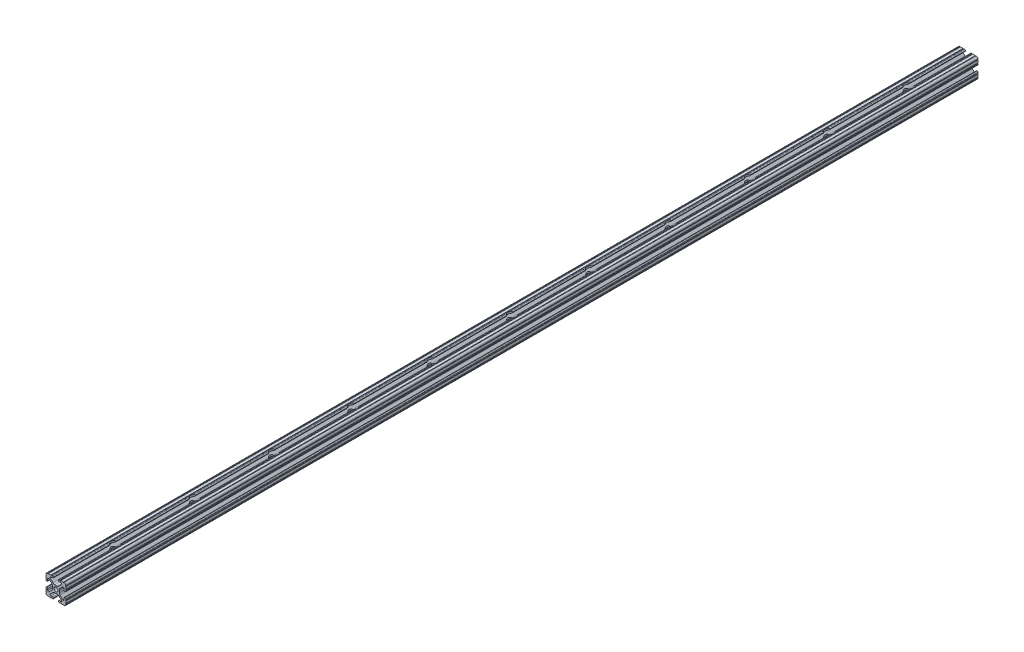
from build123d import *

# Parameters (mm, degrees)
SKETCH1_R       = 2.6035
EXTRUDE1_DEPTH  = 1168.4
LPATTERN1_COUNT = 11
LPATTERN1_PITCH = 101.6


with BuildPart() as part:
    # Sketch1 → Extrude1 (new body)
    with BuildSketch(Plane.XY):
        with BuildLine():
            Line((-7.207036008, 8.724370562), (-3.898272566, 5.423169045))
            ThreePointArc((-3.898272566, 5.423169045), (-2.869120213, 4.736787962), (-1.655778399, 4.4958))
            Line((-1.655778399, 4.4958), (1.655778399, 4.4958))
            ThreePointArc((1.655778399, 4.4958), (2.869120213, 4.736787962), (3.898272566, 5.423169045))
            Line((3.898272566, 5.423169045), (7.207036008, 8.724370562))
            ThreePointArc((7.207036008, 8.724370562), (7.432222385, 9.85140422), (6.476788598, 10.4902))
            Line((6.476788598, 10.4902), (4.287512407, 10.4902))
            ThreePointArc((4.287512407, 10.4902), (3.54574862, 10.79744862), (3.2385, 11.539212407))
            Line((3.2385, 11.539212407), (3.2385, 11.650987593))
            ThreePointArc((3.2385, 11.650987593), (3.54574862, 12.39275138), (4.287512407, 12.7))
            Line((4.287512407, 12.7), (5.317126718, 12.7))
            ThreePointArc((5.317126718, 12.7), (5.825126718, 12.192), (6.333126718, 12.7))
            Line((6.333126718, 12.7), (9.550443118, 12.7))
            ThreePointArc((9.550443118, 12.7), (10.058366869, 12.192000006), (10.566443095, 12.699847501))
            ThreePointArc((10.566443095, 12.699847501), (12.082537762, 12.08250727), (12.699846982, 10.566399977))
            ThreePointArc((12.699846982, 10.566399977), (12.192000006, 10.058323491), (12.7, 9.5504))
            Line((12.7, 9.5504), (12.7, 6.3330836))
            ThreePointArc((12.7, 6.3330836), (12.192, 5.8250836), (12.7, 5.3170836))
            Line((12.7, 5.3170836), (12.7, 4.287469289))
            ThreePointArc((12.7, 4.287469289), (12.39275138, 3.545705502), (11.650987593, 3.238456882))
            Line((11.650987593, 3.238456882), (11.539212407, 3.238456882))
            ThreePointArc((11.539212407, 3.238456882), (10.79744862, 3.545705502), (10.4902, 4.287469289))
            Line((10.4902, 4.287469289), (10.4902, 6.402089023))
            ThreePointArc((10.4902, 6.402089023), (9.856505071, 7.351067942), (8.737131347, 7.129408934))
            Line((8.737131347, 7.129408934), (5.441005833, 3.840816462))
            ThreePointArc((5.441005833, 3.840816462), (4.750877967, 2.809883091), (4.5085, 1.593185507))
            Line((4.5085, 1.593185507), (4.5085, -1.593185507))
            ThreePointArc((4.5085, -1.593185507), (4.750877967, -2.809883091), (5.441005833, -3.840816462))
            Line((5.441005833, -3.840816462), (8.737131347, -7.129408934))
            ThreePointArc((8.737131347, -7.129408934), (9.856505071, -7.351067942), (10.4902, -6.402089023))
            Line((10.4902, -6.402089023), (10.4902, -4.287469289))
            ThreePointArc((10.4902, -4.287469289), (10.79744862, -3.545705502), (11.539212407, -3.238456882))
            Line((11.539212407, -3.238456882), (11.650987593, -3.238456882))
            ThreePointArc((11.650987593, -3.238456882), (12.39275138, -3.545705502), (12.7, -4.287469289))
            Line((12.7, -4.287469289), (12.7, -5.3170836))
            ThreePointArc((12.7, -5.3170836), (12.192, -5.8250836), (12.7, -6.3330836))
            Line((12.7, -6.3330836), (12.7, -9.5504))
            ThreePointArc((12.7, -9.5504), (12.192000006, -10.058323491), (12.699846982, -10.566399977))
            ThreePointArc((12.699846982, -10.566399977), (12.082537762, -12.08250727), (10.566443095, -12.699847501))
            ThreePointArc((10.566443095, -12.699847501), (10.058366869, -12.192000006), (9.550443118, -12.7))
            Line((9.550443118, -12.7), (6.333126718, -12.7))
            ThreePointArc((6.333126718, -12.7), (5.825126718, -12.192), (5.317126718, -12.7))
            Line((5.317126718, -12.7), (4.287512407, -12.7))
            ThreePointArc((4.287512407, -12.7), (3.54574862, -12.39275138), (3.2385, -11.650987593))
            Line((3.2385, -11.650987593), (3.2385, -11.539212407))
            ThreePointArc((3.2385, -11.539212407), (3.54574862, -10.79744862), (4.287512407, -10.4902))
            Line((4.287512407, -10.4902), (6.416408329, -10.4902))
            ThreePointArc((6.416408329, -10.4902), (7.41473083, -9.822813117), (7.179650497, -8.645192506))
            Line((7.179650497, -8.645192506), (3.952270251, -5.423690499))
            ThreePointArc((3.952270251, -5.423690499), (2.922936451, -4.736929036), (1.709253557, -4.4958))
            Line((1.709253557, -4.4958), (-1.709253557, -4.4958))
            ThreePointArc((-1.709253557, -4.4958), (-2.922936451, -4.736929036), (-3.952270251, -5.423690499))
            Line((-3.952270251, -5.423690499), (-7.179650497, -8.645192506))
            ThreePointArc((-7.179650497, -8.645192506), (-7.41473083, -9.822813117), (-6.416408329, -10.4902))
            Line((-6.416408329, -10.4902), (-4.287512407, -10.4902))
            ThreePointArc((-4.287512407, -10.4902), (-3.54574862, -10.79744862), (-3.2385, -11.539212407))
            Line((-3.2385, -11.539212407), (-3.2385, -11.650987593))
            ThreePointArc((-3.2385, -11.650987593), (-3.54574862, -12.39275138), (-4.287512407, -12.7))
            Line((-4.287512407, -12.7), (-5.317126718, -12.7))
            ThreePointArc((-5.317126718, -12.7), (-5.825126718, -12.192), (-6.333126718, -12.7))
            Line((-6.333126718, -12.7), (-9.550443118, -12.7))
            ThreePointArc((-9.550443118, -12.7), (-10.058366869, -12.192000006), (-10.566443095, -12.699847501))
            ThreePointArc((-10.566443095, -12.699847501), (-12.082537762, -12.08250727), (-12.699846982, -10.566399977))
            ThreePointArc((-12.699846982, -10.566399977), (-12.192000006, -10.058323491), (-12.7, -9.5504))
            Line((-12.7, -9.5504), (-12.7, -6.3330836))
            ThreePointArc((-12.7, -6.3330836), (-12.192, -5.8250836), (-12.7, -5.3170836))
            Line((-12.7, -5.3170836), (-12.7, -4.287469289))
            ThreePointArc((-12.7, -4.287469289), (-12.39275138, -3.545705502), (-11.650987593, -3.238456882))
            Line((-11.650987593, -3.238456882), (-11.539212407, -3.238456882))
            ThreePointArc((-11.539212407, -3.238456882), (-10.79744862, -3.545705502), (-10.4902, -4.287469289))
            Line((-10.4902, -4.287469289), (-10.4902, -6.402089023))
            ThreePointArc((-10.4902, -6.402089023), (-9.856505071, -7.351067942), (-8.737131347, -7.129408934))
            Line((-8.737131347, -7.129408934), (-5.441005833, -3.840816462))
            ThreePointArc((-5.441005833, -3.840816462), (-4.750877967, -2.809883091), (-4.5085, -1.593185507))
            Line((-4.5085, -1.593185507), (-4.5085, 1.593185507))
            ThreePointArc((-4.5085, 1.593185507), (-4.750877967, 2.809883091), (-5.441005833, 3.840816462))
            Line((-5.441005833, 3.840816462), (-8.737131347, 7.129408934))
            ThreePointArc((-8.737131347, 7.129408934), (-9.856505071, 7.351067942), (-10.4902, 6.402089023))
            Line((-10.4902, 6.402089023), (-10.4902, 4.287469289))
            ThreePointArc((-10.4902, 4.287469289), (-10.79744862, 3.545705502), (-11.539212407, 3.238456882))
            Line((-11.539212407, 3.238456882), (-11.650987593, 3.238456882))
            ThreePointArc((-11.650987593, 3.238456882), (-12.39275138, 3.545705502), (-12.7, 4.287469289))
            Line((-12.7, 4.287469289), (-12.7, 5.3170836))
            ThreePointArc((-12.7, 5.3170836), (-12.192, 5.8250836), (-12.7, 6.3330836))
            Line((-12.7, 6.3330836), (-12.7, 9.5504))
            ThreePointArc((-12.7, 9.5504), (-12.192000006, 10.058323491), (-12.699846982, 10.566399977))
            ThreePointArc((-12.699846982, 10.566399977), (-12.082537762, 12.08250727), (-10.566443095, 12.699847501))
            ThreePointArc((-10.566443095, 12.699847501), (-10.058366869, 12.192000006), (-9.550443118, 12.7))
            Line((-9.550443118, 12.7), (-6.333126718, 12.7))
            ThreePointArc((-6.333126718, 12.7), (-5.825126718, 12.192), (-5.317126718, 12.7))
            Line((-5.317126718, 12.7), (-4.287512407, 12.7))
            ThreePointArc((-4.287512407, 12.7), (-3.54574862, 12.39275138), (-3.2385, 11.650987593))
            Line((-3.2385, 11.650987593), (-3.2385, 11.539212407))
            ThreePointArc((-3.2385, 11.539212407), (-3.54574862, 10.79744862), (-4.287512407, 10.4902))
            Line((-4.287512407, 10.4902), (-6.476788598, 10.4902))
            ThreePointArc((-6.476788598, 10.4902), (-7.432222385, 9.85140422), (-7.207036008, 8.724370562))
        make_face()
        Circle(SKETCH1_R, mode=Mode.SUBTRACT)
    extrude(amount=-EXTRUDE1_DEPTH)

    # Sketch2 → Hole1, 8020 No. 7256 (revolve, cut)
    with BuildSketch(Plane(origin=(0, 12.7, -76.2), x_dir=(0, 0, 1), z_dir=(1, 0, 0))):
        Polygon((0, 0), (0, 27.361148974), (3.2639, 25.4), (3.2639, 8.255), (5.1562, 8.255), (5.1562, 0), align=None)
    hole1_8020_no_7256 = revolve(axis=Axis((0, 24.010875039, -76.2), (0, -1, 0)), mode=Mode.SUBTRACT)

    # LPattern1: Hole1, 8020 No. 7256 ×11
    with Locations(*[(0, 0, -i * LPATTERN1_PITCH) for i in range(1, LPATTERN1_COUNT)]):
        add(hole1_8020_no_7256, mode=Mode.SUBTRACT)


solid = part.part
